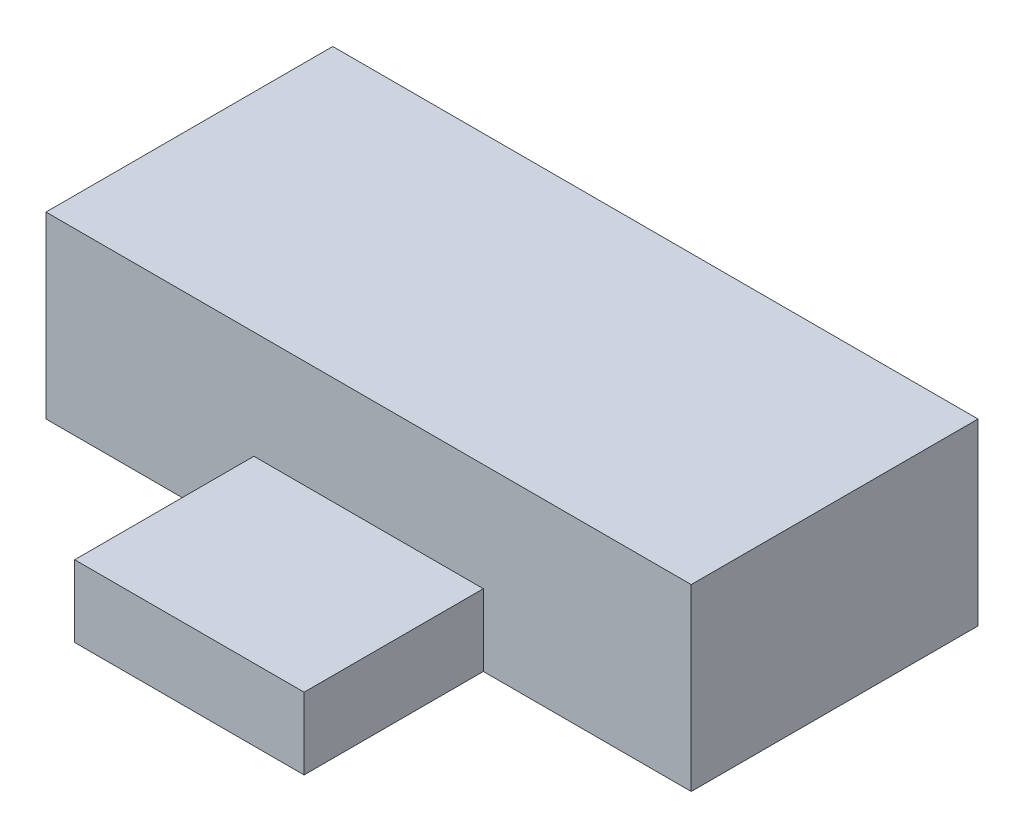
from build123d import *

# Parameters (mm, degrees)
ESQUISSE1_W        = 18
ESQUISSE1_H        = 8
BOSS_EXTRU_1_DEPTH = 5
ESQUISSE2_W        = 6.4
ESQUISSE2_H        = 2
BOSS_EXTRU_2_DEPTH = 5


with BuildPart() as part:
    # Esquisse1 → Boss.-Extru.1 (new body)
    with BuildSketch(Plane(origin=(0, 0, 0), x_dir=(1, 0, 0), z_dir=(0, 1, 0))):
        Rectangle(ESQUISSE1_W, ESQUISSE1_H)
    extrude(amount=BOSS_EXTRU_1_DEPTH)

    # Esquisse2 → Boss.-Extru.2 (add)
    with BuildSketch(Plane.XY.offset(4)):
        with Locations((0, 1)):
            Rectangle(ESQUISSE2_W, ESQUISSE2_H)
    extrude(amount=BOSS_EXTRU_2_DEPTH)


solid = part.part
